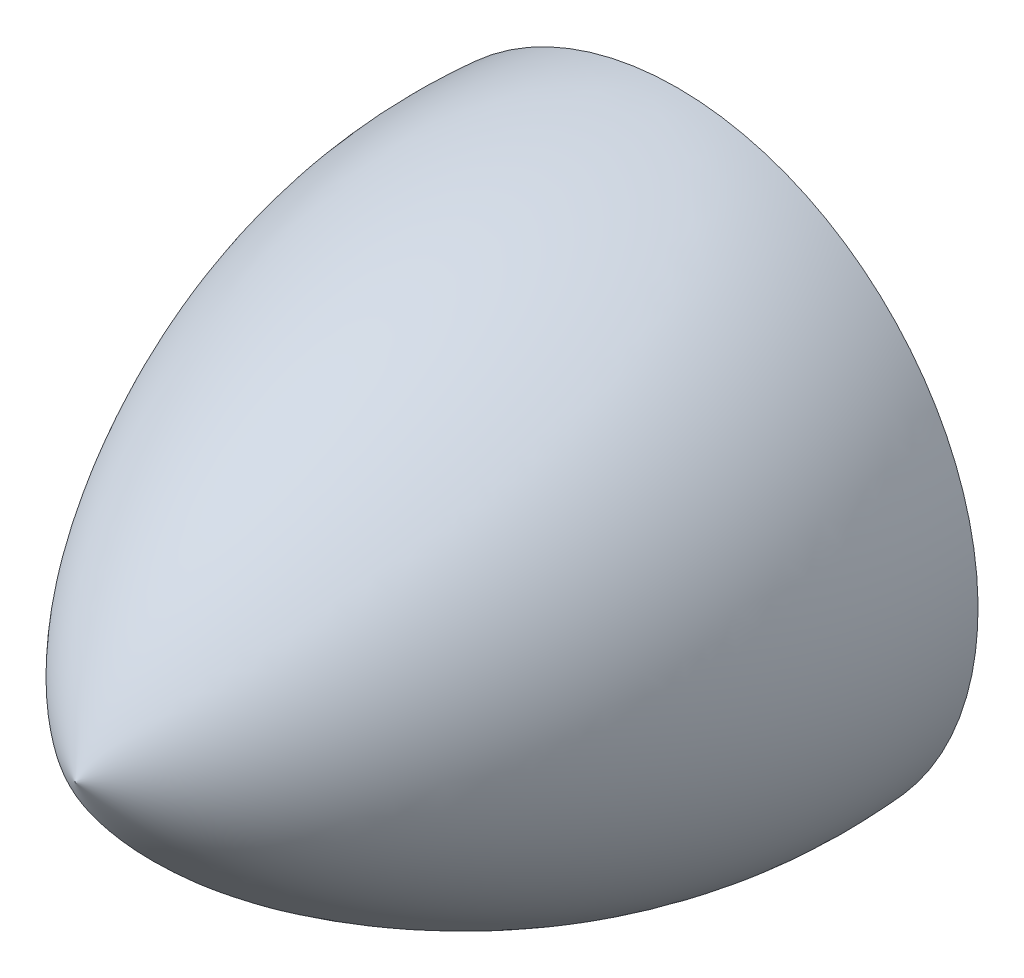
from build123d import *


with BuildPart() as part:
    # Sketch1 one side → Revolve1 (revolve)
    with BuildSketch(Plane(origin=(0, 0, 0), x_dir=(0, 0, -1), z_dir=(1, 0, 0))):
        with BuildLine():
            Line((-70.104, 0), (0, 0))
            Line((0, 0), (0, 35))
            add(Edge.make_bspline(
                [(-70.104, 0), (-64.61877021, 11.169619974), (-42.348010529, 28.804891159), (-15.522027433, 36.222966989), (0, 35)],
                knots=[0, 0, 0, 0, 0.446109601, 1, 1, 1, 1], degree=3))
        make_face()
    revolve(axis=Axis((0, 0, 0), (0, 0, 1)))


solid = part.part
